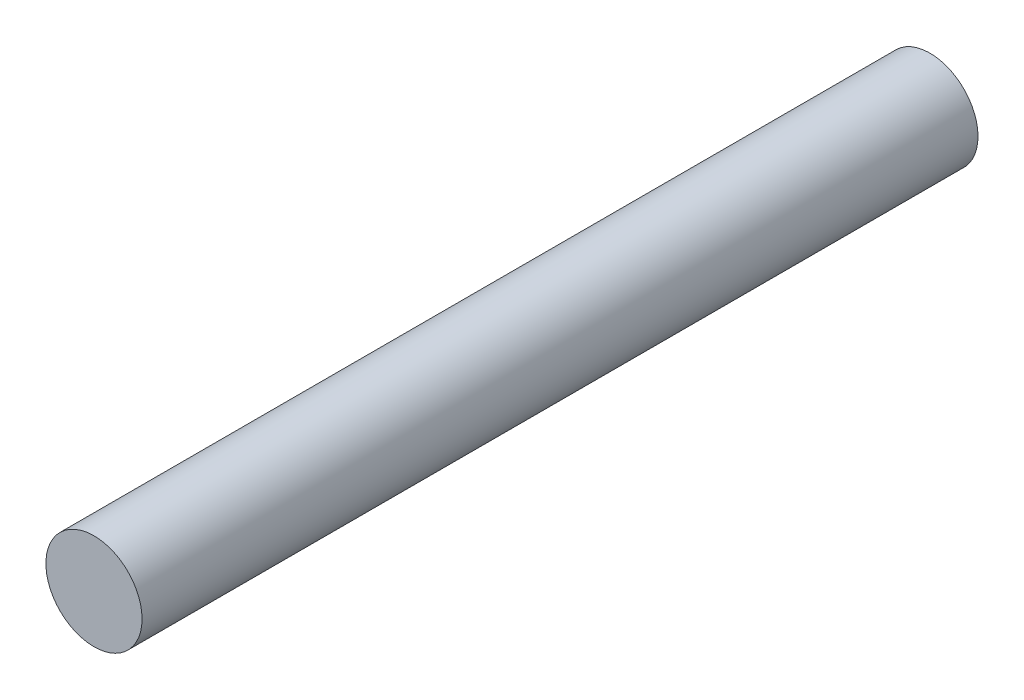
from build123d import *

# Parameters (mm, degrees)
SKETCH1_R           = 5.842
BOSS_EXTRUDE2_DEPTH = 101.6


with BuildPart() as part:
    # Sketch1 → Boss-Extrude2 (new body)
    with BuildSketch(Plane.XY):
        Circle(SKETCH1_R)
    extrude(amount=BOSS_EXTRUDE2_DEPTH)


solid = part.part
